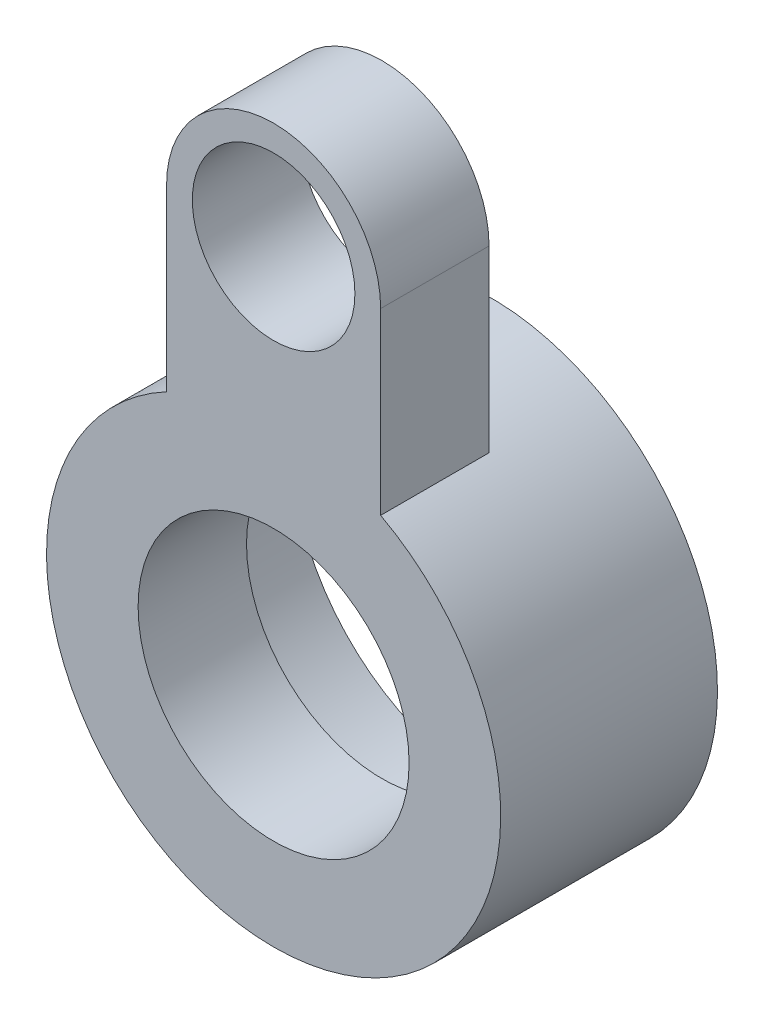
from build123d import *

# Parameters (mm, degrees)
SKETCH1_R           = 10
SKETCH1_R_2         = 1.5000000000000004
SKETCH1_R_3         = 2.5
BOSS_EXTRUDE1_DEPTH = 2
CUT_EXTRUDE1_START  = -10
SKETCH2_R           = 10
CUT_EXTRUDE1_DEPTH  = 10
BOSS_EXTRUDE3_START = 2
SKETCH4_R           = 4.1899999999999995
SKETCH4_R_2         = 3.667149527921724
BOSS_EXTRUDE3_DEPTH = 2


with BuildPart() as part:
    # Sketch1 → Boss-Extrude1 (new body)
    with BuildSketch(Plane.XY):
        Circle(SKETCH1_R)
        with Locations((0, 7)):
            Circle(SKETCH1_R_2, mode=Mode.SUBTRACT)
        Circle(SKETCH1_R_3, mode=Mode.SUBTRACT)
    extrude(amount=BOSS_EXTRUDE1_DEPTH)

    # Sketch2 → Cut-Extrude1 (cut)
    with BuildSketch(Plane.XY.offset(2).offset(CUT_EXTRUDE1_START)):
        Circle(SKETCH2_R)
        with BuildLine():
            Line((-1.975, 7), (-1.9749999999999994, 3.6953315142216945))
            ThreePointArc((-1.9749999999999994, 3.6953315142216945), (-3.593838477171726, 2.1541645712433404), (-4.1899999999999995, 0))
            ThreePointArc((-4.1899999999999995, 0), (-7.7e-16, -4.1899999999999995), (4.189999999999998, 3.47e-15))
            ThreePointArc((4.189999999999998, 3.47e-15), (3.5938384771717247, 2.1541645712433426), (1.9749999999999959, 3.6953315142216963))
            Line((1.9749999999999959, 3.6953315142216963), (1.974999999999994, 7.000000000000001))
            ThreePointArc((1.974999999999994, 7.000000000000001), (-3.2e-16, 8.974999999999994), (-1.975, 7))
        make_face(mode=Mode.SUBTRACT)
    extrude(amount=CUT_EXTRUDE1_DEPTH, mode=Mode.SUBTRACT)

    # Sketch4 → Boss-Extrude3 (add)
    with BuildSketch(Plane(origin=(0, 0, 0), x_dir=(-1, 0, 0), z_dir=(0, 0, -1)).offset(BOSS_EXTRUDE3_START)):
        with Locations(Location((0, 0, 0), (0, 0, 118.122638153))):
            Circle(SKETCH4_R)
        Circle(SKETCH4_R_2, mode=Mode.SUBTRACT)
    extrude(amount=-BOSS_EXTRUDE3_DEPTH)


solid = part.part
